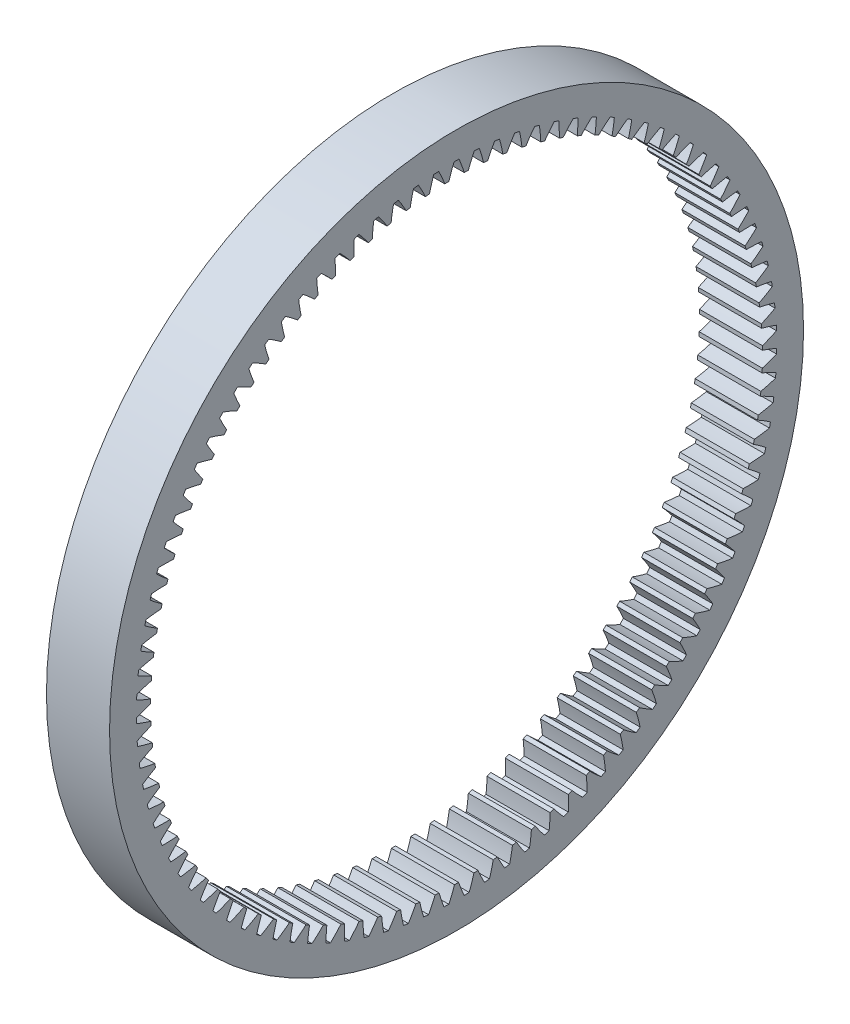
from build123d import *

# Parameters (mm, degrees)
BASPROSKE_W     = 5
BASPROSKE_H     = 3.25
TOOTHCUT_DEPTH  = 40.210967853
TEETHCUTS_COUNT = 99
TEETHCUTS_ANGLE = 356.363636364


with BuildPart() as part:
    # BasProSke → Base-Revolve (revolve)
    with BuildSketch(Plane(origin=(0, 0, 0), x_dir=(1, 0, 0), z_dir=(0, 1, 0)), mode=Mode.PRIVATE) as base_revolve_sk:
        with Locations((2.5, 25.875)):
            Rectangle(BASPROSKE_W, BASPROSKE_H)
    revolve(base_revolve_sk.sketch.rotate(Axis((-10, 0, 0), (1, 0, 0)), 180), axis=Axis((-10, 0, 0), (1, 0, 0)))

    # TooCutSke → ToothCut (cut, through all)
    with BuildSketch(Plane(origin=(0, 0, 0), x_dir=(0, 0, -1), z_dir=(1, 0, 0))):
        with BuildLine():
            ThreePointArc((0.615764182, 24.216772692), (0.420351415, 24.801234088), (0.196084323, 25.375242402))
            ThreePointArc((0.196084323, 25.375242402), (0, 25.376), (-0.196084323, 25.375242402))
            ThreePointArc((-0.196084323, 25.375242402), (-0.420351415, 24.801234088), (-0.615764182, 24.216772692))
            ThreePointArc((-0.615764182, 24.216772692), (0, 24.2246), (0.615764182, 24.216772692))
        make_face()
    toothcut = extrude(amount=TOOTHCUT_DEPTH, mode=Mode.SUBTRACT)

    # TeethCuts: ToothCut ×99 about axis
    teethcuts_axis = Axis((-10, 0, 0), (1, 0, 0))
    for i in range(1, TEETHCUTS_COUNT):
        add(toothcut.rotate(teethcuts_axis, i * TEETHCUTS_ANGLE / (TEETHCUTS_COUNT - 1)), mode=Mode.SUBTRACT)


solid = part.part
